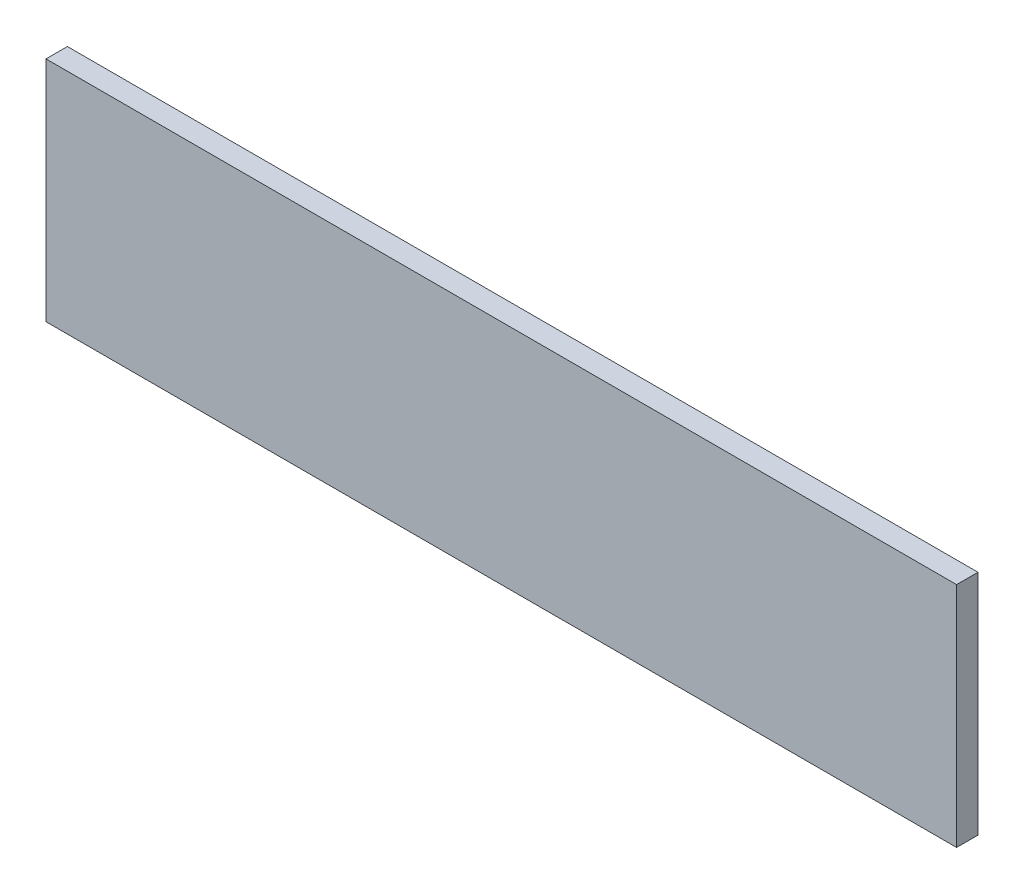
from build123d import *

# Parameters (mm, degrees)
SKETCH1_W           = 508
SKETCH1_H           = 127
BOSS_EXTRUDE1_DEPTH = 11.938


with BuildPart() as part:
    # Sketch1 → Boss-Extrude1 (new body)
    with BuildSketch(Plane.XY):
        Rectangle(SKETCH1_W, SKETCH1_H)
    extrude(amount=BOSS_EXTRUDE1_DEPTH)


solid = part.part
